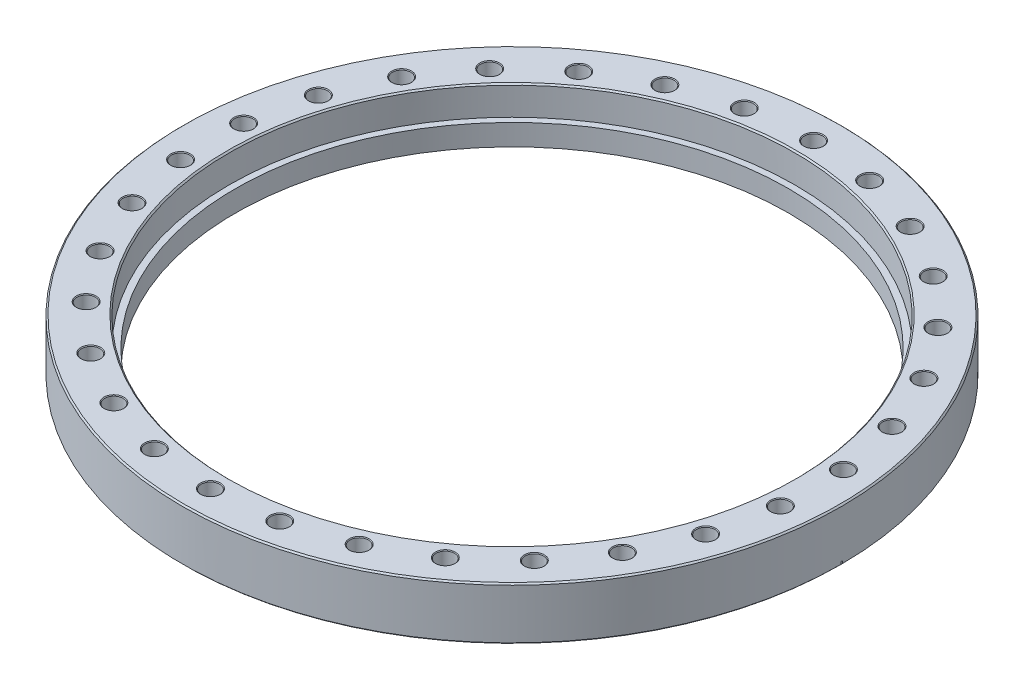
from build123d import *

# Parameters (mm, degrees)
SKETCH1_R                    = 177.8
SKETCH1_R_2                  = 149.225
BOSS_EXTRUDE1_DEPTH          = 28.448
SKETCH2_R                    = 152.654
CUT_EXTRUDE1_DEPTH           = 15.748
CHAMFER1_SIZE                = 0.762
SKETCH3_R                    = 4.953
CUT_EXTRUDE2_DEPTH           = 29.448
CHAMFER2_SIZE                = 0.381
CIRPATTERN1_COUNT            = 30
CHAMFER2_OF_CIRPATTERN1_SIZE = 0.381
CUT_EXTRUDE3_DEPTH           = 0.381


with BuildPart() as part:
    # Sketch1 → Boss-Extrude1 (new body)
    with BuildSketch(Plane(origin=(0, 0, 0), x_dir=(1, 0, 0), z_dir=(0, 1, 0))):
        Circle(SKETCH1_R)
        Circle(SKETCH1_R_2, mode=Mode.SUBTRACT)
    extrude(amount=BOSS_EXTRUDE1_DEPTH)

    # Sketch2 → Cut-Extrude1 (cut)
    with BuildSketch(Plane(origin=(0, 28.448, 0), x_dir=(-1, 0, 0), z_dir=(0, -1, 0))):
        Circle(SKETCH2_R)
    extrude(amount=CUT_EXTRUDE1_DEPTH, mode=Mode.SUBTRACT)

    # Chamfer1
    chamfer1_edges = [part.edges().sort_by_distance(p)[0] for p in [
        (152.654, 28.448, 0),
        (-177.8, 0, 0),
        (-177.8, 28.448, 0),
    ]]
    chamfer(chamfer1_edges, length=CHAMFER1_SIZE)

    # Sketch4 → Cut-Revolve1 (revolve, cut)
    with BuildSketch(Plane.XY):
        Polygon((-156.845, 0), (-156.845, 1.816005512), (-153.67, 0.6604), (-153.67, 1.27), (0, 1.27), (0, 0), align=None)
    revolve(axis=Axis((0, 28.448, 0), (0, -1, 0)), mode=Mode.SUBTRACT)

    # Sketch3 → Cut-Extrude2 (cut, through all)
    with BuildSketch(Plane(origin=(0, 28.448, 0), x_dir=(1, 0, 0), z_dir=(0, 1, 0))):
        with Locations((0, 162.687)):
            Circle(SKETCH3_R)
    cut_extrude2 = extrude(amount=-CUT_EXTRUDE2_DEPTH, mode=Mode.SUBTRACT)

    # Chamfer2
    chamfer2_edges = [part.edges().sort_by_distance(p)[0] for p in [
        (-4.953, 0, -162.687),
        (-4.953, 28.448, -162.687),
    ]]
    chamfer(chamfer2_edges, length=CHAMFER2_SIZE)

    # CirPattern1: Cut-Extrude2 ×30 about axis
    cirpattern1_axis = Axis((0, 0, 0), (0, 1, 0))
    for i in range(1, CIRPATTERN1_COUNT):
        add(cut_extrude2.rotate(cirpattern1_axis, i * 360 / CIRPATTERN1_COUNT), mode=Mode.SUBTRACT)

    # Chamfer2 of CirPattern1
    chamfer2_of_cirpattern1_edges = [part.edges().sort_by_distance(p)[0] for p in [
        (-38.669294311, 0, -158.102112116),
        (-38.669294311, 28.448, -158.102112116),
        (-70.695554904, 0, -146.607403274),
        (-70.695554904, 28.448, -146.607403274),
        (-99.632080513, 0, -128.705247409),
        (-99.632080513, 28.448, -128.705247409),
        (-124.214206116, 0, -105.178054636),
        (-124.214206116, 28.448, -105.178054636),
        (-143.367574865, 0, -77.054076175),
        (-143.367574865, 28.448, -77.054076175),
        (-156.25509264, 0, -45.562464839),
        (-156.25509264, 28.448, -45.562464839),
        (-162.31351307, 0, -12.079555156),
        (-162.31351307, 28.448, -12.079555156),
        (-161.278054113, 0, 21.931289051),
        (-161.278054113, 28.448, 21.931289051),
        (-153.193970293, 0, 54.983630689),
        (-153.193970293, 28.448, 54.983630689),
        (-138.414574865, 0, 85.632923825),
        (-138.414574865, 28.448, 85.632923825),
        (-117.585798329, 0, 112.539647277),
        (-117.585798329, 28.448, 112.539647277),
        (-91.617958167, 0, 134.527848118),
        (-91.617958167, 28.448, 134.527848118),
        (-61.6459736, 0, 150.636536461),
        (-61.6459736, 28.448, 150.636536461),
        (-28.979764178, 0, 160.161685325),
        (-28.979764178, 28.448, 160.161685325),
        (4.953, 0, 162.687),
        (4.953, 28.448, 162.687),
        (38.669294311, 0, 158.102112116),
        (38.669294311, 28.448, 158.102112116),
        (70.695554904, 0, 146.607403274),
        (70.695554904, 28.448, 146.607403274),
        (99.632080513, 0, 128.705247409),
        (99.632080513, 28.448, 128.705247409),
        (124.214206116, 0, 105.178054636),
        (124.214206116, 28.448, 105.178054636),
        (143.367574865, 0, 77.054076175),
        (143.367574865, 28.448, 77.054076175),
        (156.25509264, 0, 45.562464839),
        (156.25509264, 28.448, 45.562464839),
        (162.31351307, 0, 12.079555156),
        (162.31351307, 28.448, 12.079555156),
        (161.278054113, 0, -21.931289051),
        (161.278054113, 28.448, -21.931289051),
        (153.193970293, 0, -54.983630689),
        (153.193970293, 28.448, -54.983630689),
        (138.414574865, 0, -85.632923825),
        (138.414574865, 28.448, -85.632923825),
        (117.585798329, 0, -112.539647277),
        (117.585798329, 28.448, -112.539647277),
        (91.617958167, 0, -134.527848118),
        (91.617958167, 28.448, -134.527848118),
        (61.6459736, 0, -150.636536461),
        (61.6459736, 28.448, -150.636536461),
        (28.979764178, 0, -160.161685325),
        (28.979764178, 28.448, -160.161685325),
    ]]
    chamfer(chamfer2_of_cirpattern1_edges, length=CHAMFER2_OF_CIRPATTERN1_SIZE)

    # Sketch5 → Cut-Extrude3 (cut, symmetric)
    with BuildSketch(Plane.XY):
        Polygon((-155.45787474, 0.893727035), (-177.8, 2.064628205), (-177.8, -7.253474952), (-155.45787474, -7.253474952), align=None)
        Polygon((155.45787474, 0.893727035), (155.45787474, -7.253474952), (177.8, -7.253474952), (177.8, 2.064628205), align=None)
    extrude(amount=CUT_EXTRUDE3_DEPTH, both=True, mode=Mode.SUBTRACT)


solid = part.part
